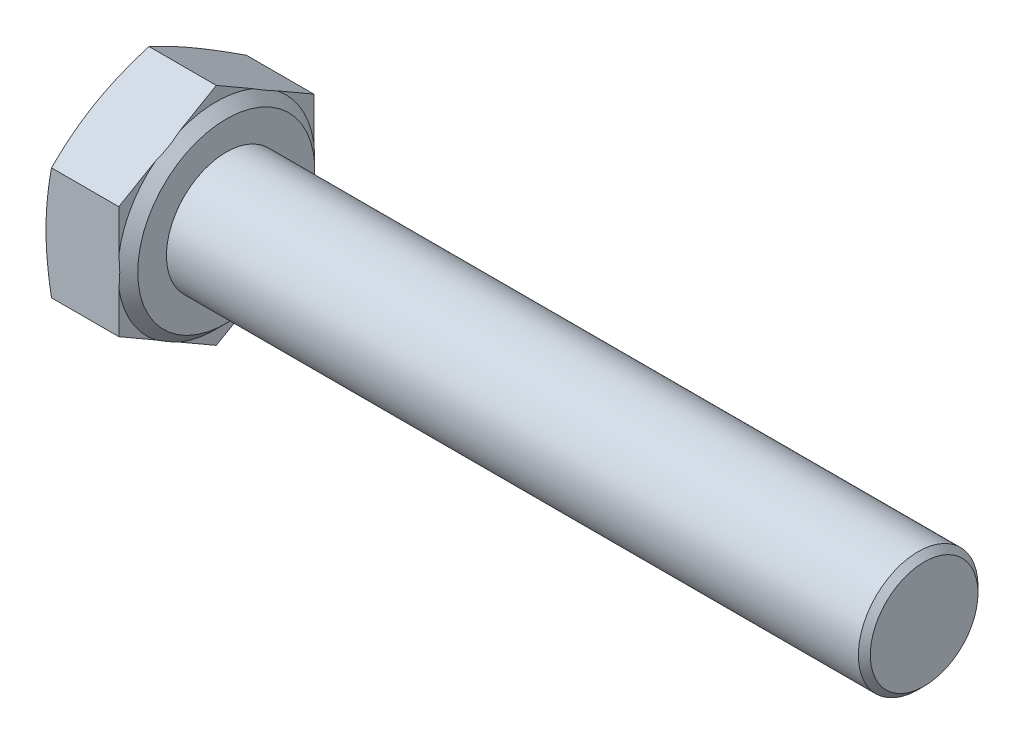
from build123d import *

# Parameters (mm, degrees)
BASEHEAD_DEPTH = 4.15
SKETCH5_R      = 3
BASEBODY_DEPTH = 35
CHAMFER1_SIZE  = 0.3


with BuildPart() as part:
    # Sketch2 → BaseHead (new body)
    with BuildSketch(Plane(origin=(0, 0, 0), x_dir=(0, 0, -1), z_dir=(1, 0, 0))):
        Polygon((4.89, -2.823242816), (4.89, 2.823242816), (0, 5.646485633), (-4.89, 2.823242816), (-4.89, -2.823242816), (0, -5.646485633), align=None)
    extrude(amount=BASEHEAD_DEPTH)

    # Sketch3 → BearingFace (revolve, cut)
    with BuildSketch(Plane.XY):
        Polygon((4.15, 5.646485633), (4.15, 4.44), (3.65, 4.94), (3.65, 5.646485633), align=None)
    revolve(axis=Axis((-0.957090588, 0, 0), (1, 0, 0)), mode=Mode.SUBTRACT)

    # Sketch4 → HeadChamfer (revolve, cut)
    with BuildSketch(Plane.XY):
        Polygon((0, 5.646485633), (0.275338253, 5.646485633), (0, 4.89), align=None)
    revolve(axis=Axis((-0.493528746, 0, 0), (1, 0, 0)), mode=Mode.SUBTRACT)

    # Sketch5 → BaseBody (add)
    with BuildSketch(Plane(origin=(4.15, 0, 0), x_dir=(0, 0, -1), z_dir=(1, 0, 0))):
        Circle(SKETCH5_R)
    extrude(amount=BASEBODY_DEPTH)

    # Chamfer1
    chamfer1_edges = [part.edges().sort_by_distance(p)[0] for p in [
        (39.15, 0, 3),
    ]]
    chamfer(chamfer1_edges, length=CHAMFER1_SIZE)


solid = part.part
